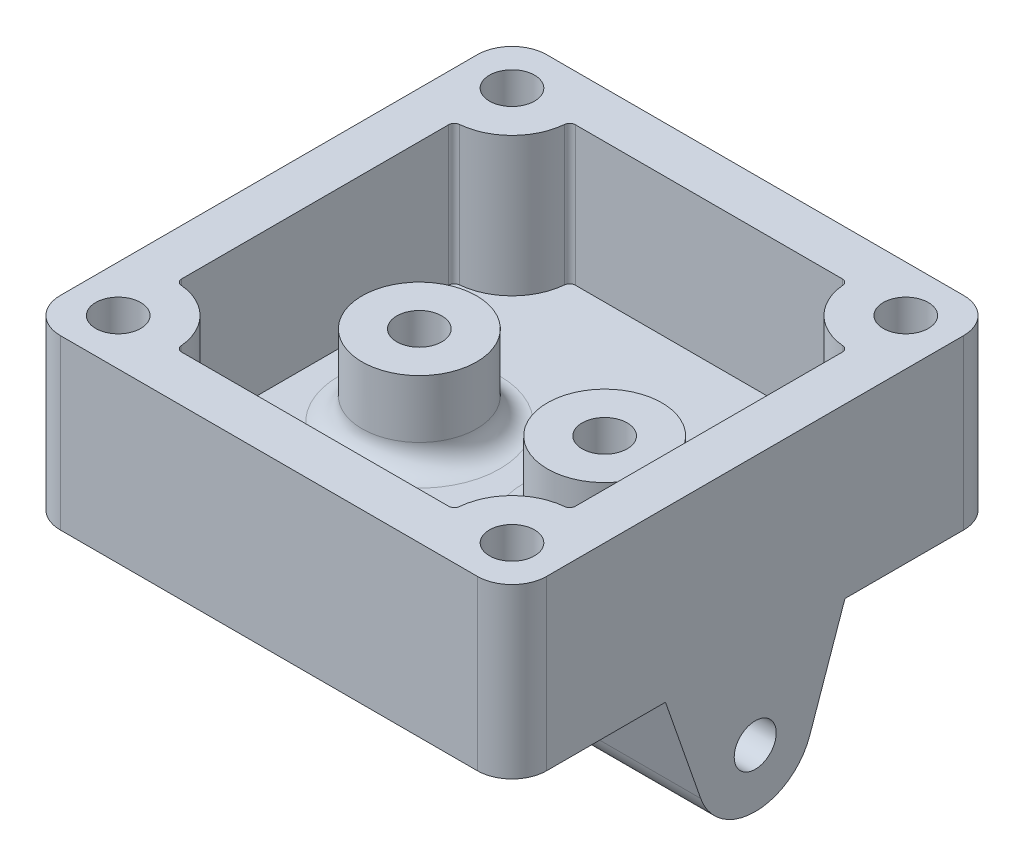
from build123d import *

# Parameters (mm, degrees)
SKETCH1_W           = 42
SKETCH1_H           = 42
BOSS_EXTRUDE1_DEPTH = 2.54
SKETCH2_W           = 42
SKETCH2_H           = 42
BOSS_EXTRUDE2_DEPTH = 12
SKETCH4_R           = 1.813765306
BOSS_EXTRUDE4_DEPTH = 42
SKETCH9_R           = 4.945
SKETCH9_R_2         = 1.945
BOSS_EXTRUDE5_DEPTH = 7
SKETCH10_R          = 1.945
CUT_EXTRUDE1_DEPTH  = 8
FILLET1_R           = 3
FILLET3_R           = 2


with BuildPart() as part:
    # Sketch1 → Boss-Extrude1 (new body)
    with BuildSketch(Plane(origin=(0, 0, 0), x_dir=(1, 0, 0), z_dir=(0, 1, 0))):
        Rectangle(SKETCH1_W, SKETCH1_H)
    extrude(amount=BOSS_EXTRUDE1_DEPTH)

    # Sketch2 → Boss-Extrude2 (add)
    with BuildSketch(Plane(origin=(0, 2.54, 0), x_dir=(1, 0, 0), z_dir=(0, 1, 0))):
        Rectangle(SKETCH2_W, SKETCH2_H)
        with BuildLine():
            Line((-17, 11.522774425), (-17, -11.522774425))
            ThreePointArc((-17, -11.522774425), (-16.869274473, -11.859874356), (-16.545454545, -12.020704023))
            ThreePointArc((-16.545454545, -12.020704023), (-13.464466094, -13.464466094), (-12.020704023, -16.545454545))
            ThreePointArc((-12.020704023, -16.545454545), (-11.859874356, -16.869274473), (-11.522774425, -17))
            Line((-11.522774425, -17), (11.522774425, -17))
            ThreePointArc((11.522774425, -17), (11.859874356, -16.869274473), (12.020704023, -16.545454545))
            ThreePointArc((12.020704023, -16.545454545), (13.464466094, -13.464466094), (16.545454545, -12.020704023))
            ThreePointArc((16.545454545, -12.020704023), (16.869274473, -11.859874356), (17, -11.522774425))
            Line((17, -11.522774425), (17, 11.522774425))
            ThreePointArc((17, 11.522774425), (16.869274473, 11.859874356), (16.545454545, 12.020704023))
            ThreePointArc((16.545454545, 12.020704023), (13.464466094, 13.464466094), (12.020704023, 16.545454545))
            ThreePointArc((12.020704023, 16.545454545), (11.859874356, 16.869274473), (11.522774425, 17))
            Line((11.522774425, 17), (-11.522774425, 17))
            ThreePointArc((-11.522774425, 17), (-11.859874356, 16.869274473), (-12.020704023, 16.545454545))
            ThreePointArc((-12.020704023, 16.545454545), (-13.464466094, 13.464466094), (-16.545454545, 12.020704023))
            ThreePointArc((-16.545454545, 12.020704023), (-16.869274473, 11.859874356), (-17, 11.522774425))
        make_face(mode=Mode.SUBTRACT)
    extrude(amount=BOSS_EXTRUDE2_DEPTH)

    # Sketch4 → Boss-Extrude4 (add)
    with BuildSketch(Plane.ZY.offset(21)):
        with BuildLine():
            Line((7.748459825, 0), (4.708955343, -8.719310622))
            ThreePointArc((4.708955343, -8.719310622), (0, -12.064660663), (-4.708955343, -8.719310622))
            Line((-4.708955343, -8.719310622), (-7.748459825, 0))
            Line((-7.748459825, 0), (7.748459825, 0))
        make_face()
        with Locations((0, -7.077794281)):
            Circle(SKETCH4_R, mode=Mode.SUBTRACT)
    extrude(amount=-BOSS_EXTRUDE4_DEPTH)

    # Sketch9 → Boss-Extrude5 (add)
    with BuildSketch(Plane(origin=(0, 2.54, 0), x_dir=(1, 0, 0), z_dir=(0, 1, 0))):
        with Locations((8, 0)):
            Circle(SKETCH9_R)
        with Locations((8, 0)):
            Circle(SKETCH9_R_2, mode=Mode.SUBTRACT)
        with Locations((-8, 0)):
            Circle(SKETCH9_R)
        with Locations((-8, 0)):
            Circle(SKETCH9_R_2, mode=Mode.SUBTRACT)
    extrude(amount=BOSS_EXTRUDE5_DEPTH)

    # Sketch10 → Cut-Extrude1 (cut)
    with BuildSketch(Plane(origin=(0, 14.54, 0), x_dir=(1, 0, 0), z_dir=(0, 1, 0))):
        with Locations((-17, 17)):
            Circle(SKETCH10_R)
        with Locations((17, 17)):
            Circle(SKETCH10_R)
        with Locations((-17, -17)):
            Circle(SKETCH10_R)
        with Locations((17, -17)):
            Circle(SKETCH10_R)
    extrude(amount=-CUT_EXTRUDE1_DEPTH, mode=Mode.SUBTRACT)

    # Fillet1
    fillet1_edges = [part.edges().sort_by_distance(p)[0] for p in [
        (21, 7.27, 21),
        (-21, 7.27, 21),
        (-21, 7.27, -21),
        (21, 7.27, -21),
    ]]
    fillet(fillet1_edges, radius=FILLET1_R)

    # Fillet3
    fillet3_edges = [part.edges().sort_by_distance(p)[0] for p in [
        (3.055, 2.54, 0),
        (-12.945, 2.54, 0),
    ]]
    fillet(fillet3_edges, radius=FILLET3_R)


solid = part.part
